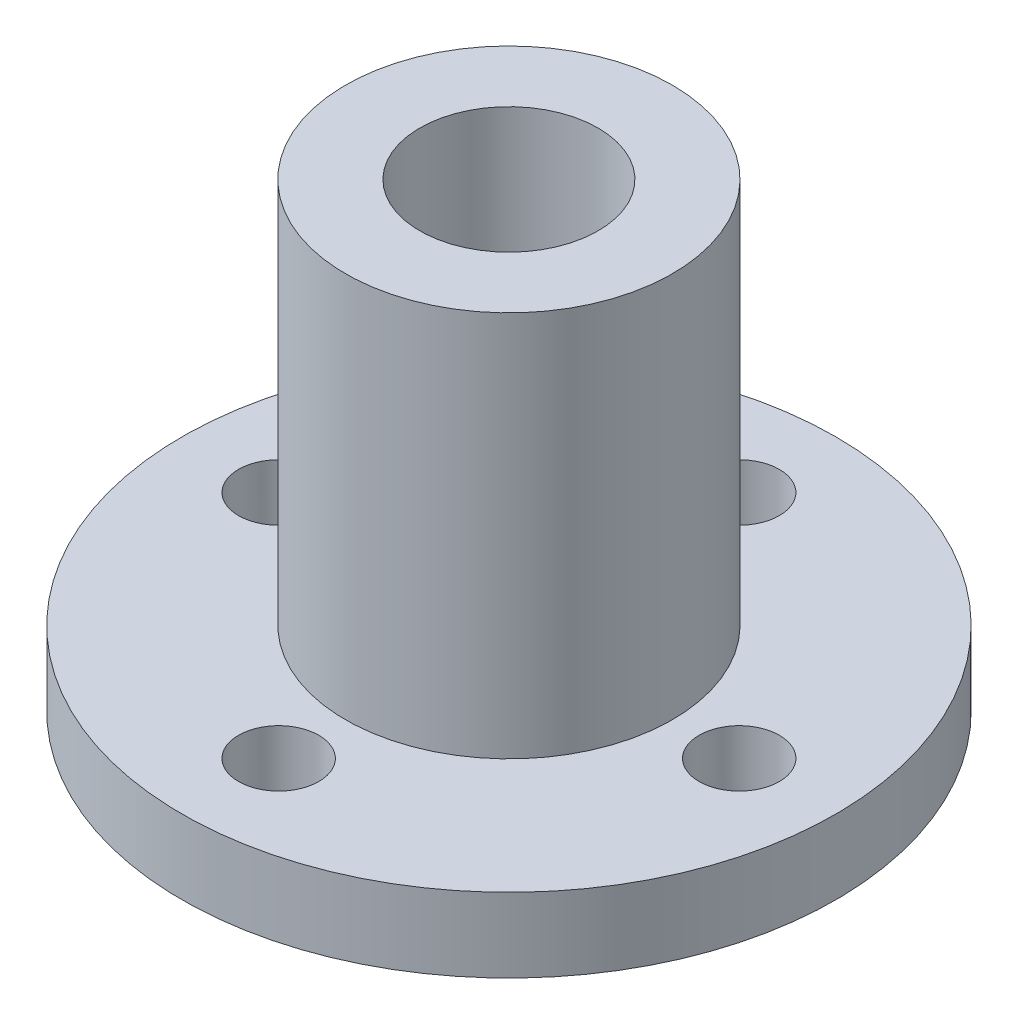
from build123d import *

# Parameters (mm, degrees)
SKETCH2_R          = 2.7
CUT_EXTRUDE1_DEPTH = 10


with BuildPart() as part:
    # Sketch1 → Revolve1 (revolve)
    with BuildSketch(Plane.XY, mode=Mode.PRIVATE) as revolve1_sk:
        Polygon((6, 0), (22, 0), (22, 5), (11, 5), (11, 31), (6, 31), align=None)
    revolve(revolve1_sk.sketch.rotate(Axis((0, 0, 0), (0, 1, 0)), 90), axis=Axis((0, 0, 0), (0, 1, 0)))  # turned: the seam where the file's is

    # Sketch2 → Cut-Extrude1 (cut)
    with BuildSketch(Plane.XZ):
        with Locations(Location((0, 15.5, 0), (0, 0, 270))):  # turned: the seam where the file's is
            Circle(SKETCH2_R)
        with Locations(Location((15.5, 0, 0), (0, 0, 270))):  # turned: the seam where the file's is
            Circle(SKETCH2_R)
        with Locations(Location((0, -15.5, 0), (0, 0, 270))):  # turned: the seam where the file's is
            Circle(SKETCH2_R)
        with Locations(Location((-15.5, 0, 0), (0, 0, 270))):  # turned: the seam where the file's is
            Circle(SKETCH2_R)
    extrude(amount=-CUT_EXTRUDE1_DEPTH, mode=Mode.SUBTRACT)


solid = part.part
